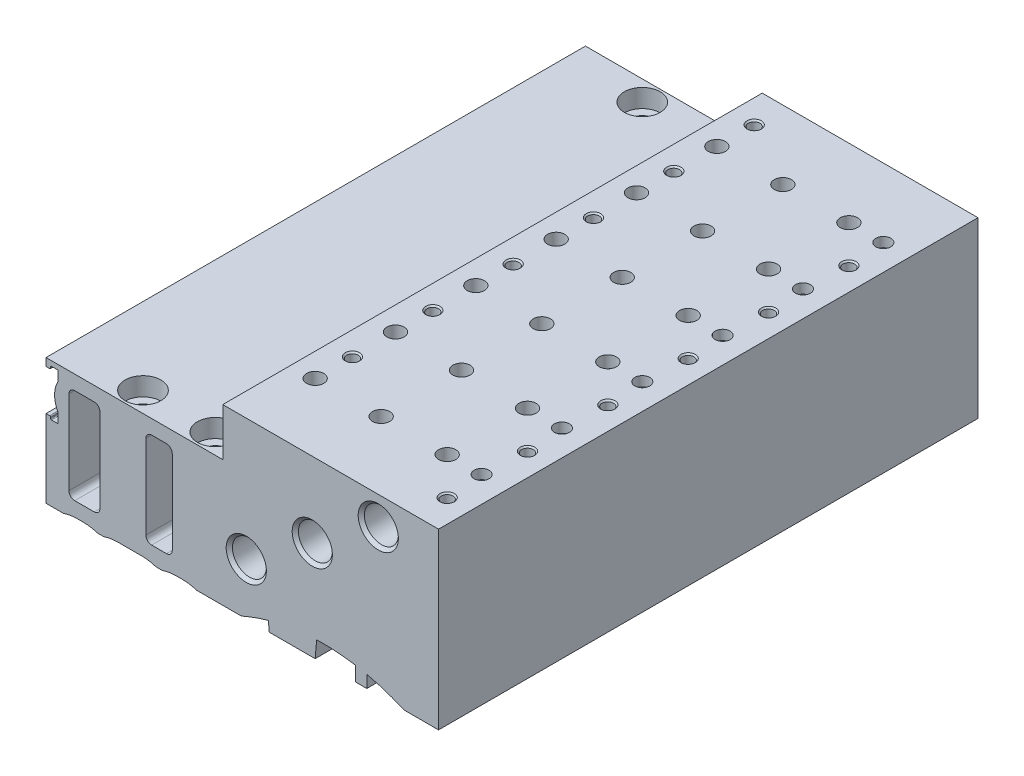
from build123d import *

# Parameters (mm, degrees)
BOSS_EXTRUDE1_DEPTH = 94
HOLE1_D             = 3.7
HOLE1_DEPTH         = 9
HOLE1_TIP           = 1.068097998
HOLE2_D             = 3.7
HOLE2_DEPTH         = 9
HOLE2_TIP           = 1.068097998
SKETCH13_R          = 1.5
CUT_EXTRUDE1_DEPTH  = 7
LPATTERN1_COUNT     = 6
LPATTERN1_PITCH     = 14
SKETCH15_R          = 1.5
CUT_EXTRUDE2_DEPTH  = 12
LPATTERN2_COUNT     = 6
LPATTERN2_PITCH     = 14
SKETCH17_R          = 1.5
CUT_EXTRUDE3_DEPTH  = 22
LPATTERN3_COUNT     = 6
LPATTERN3_PITCH     = 14
SKETCH19_R          = 1.3
CUT_EXTRUDE4_DEPTH  = 1.7
LPATTERN4_COUNT     = 6
LPATTERN4_PITCH     = 14
LPATTERN5_COUNT     = 6
LPATTERN5_PITCH     = 14
LPATTERN6_COUNT     = 6
LPATTERN6_PITCH     = 14


with BuildPart() as part:
    # Sketch1 → Boss-Extrude1 (new body)
    with BuildSketch(Plane.XY):
        with BuildLine():
            Line((-68.4, 20.65), (-67.75, 20.65))
            ThreePointArc((-67.75, 20.65), (-67.643933983, 20.693933983), (-67.6, 20.8))
            Line((-67.6, 20.8), (-67.6, 21))
            ThreePointArc((-67.6, 21), (-67.556066017, 21.106066017), (-67.45, 21.15))
            Line((-67.45, 21.15), (-66.45, 21.15))
            ThreePointArc((-66.45, 21.15), (-66.343933983, 21.106066017), (-66.3, 21))
            Line((-66.3, 21), (-66.3, 19.423790008))
            ThreePointArc((-66.3, 19.423790008), (-66.9, 17.1), (-66.3, 14.776209992))
            Line((-66.3, 14.776209992), (-66.3, 13.2))
            ThreePointArc((-66.3, 13.2), (-66.343933983, 13.093933983), (-66.45, 13.05))
            Line((-66.45, 13.05), (-67.45, 13.05))
            ThreePointArc((-67.45, 13.05), (-67.556066017, 13.093933983), (-67.6, 13.2))
            Line((-67.6, 13.2), (-67.6, 13.4))
            ThreePointArc((-67.6, 13.4), (-67.643933983, 13.506066017), (-67.75, 13.55))
            Line((-67.75, 13.55), (-68.4, 13.55))
            Line((-68.4, 13.55), (-68.4, 0))
            Line((-68.4, 0), (-65.399489743, 0))
            ThreePointArc((-65.399489743, 0), (-64.190967365, 0.299342077), (-62.95, 0.4))
            Line((-62.95, 0.4), (-61.9, 0.4))
            ThreePointArc((-61.9, 0.4), (-60.659032635, 0.299342077), (-59.450510257, 0))
            Line((-59.450510257, 0), (-58.349489743, 0))
            ThreePointArc((-58.349489743, 0), (-57.140967365, 0.299342077), (-55.9, 0.4))
            Line((-55.9, 0.4), (-51.7, 0.4))
            ThreePointArc((-51.7, 0.4), (-50.459032635, 0.299342077), (-49.250510257, 0))
            Line((-49.250510257, 0), (-48.149489743, 0))
            ThreePointArc((-48.149489743, 0), (-46.940967365, 0.299342077), (-45.7, 0.4))
            Line((-45.7, 0.4), (-44.6, 0.4))
            ThreePointArc((-44.6, 0.4), (-43.359032635, 0.299342077), (-42.150510257, 0))
            Line((-42.150510257, 0), (-34.377446879, 0))
            ThreePointArc((-34.377446879, 0), (-32.04366607, 0.935202656), (-29.648770622, 1.700455987))
            Line((-29.648770622, 1.700455987), (-29.5, 0))
            Line((-29.5, 0), (-21.5, 0))
            Line((-21.5, 0), (-21.23888323, 2.98457834))
            ThreePointArc((-21.23888323, 2.98457834), (-17.858517075, 2.921590137), (-14.5, 2.53273809))
            Line((-14.5, 2.53273809), (-14.5, 0))
            Line((-14.5, 0), (-12.5, 0))
            Line((-12.5, 0), (-12.5, 2.142495515))
            ThreePointArc((-12.5, 2.142495515), (-9.208947173, 1.229456176), (-6.022553121, 0))
            Line((-6.022553121, 0), (0, 0))
            Line((0, 0), (0, 30.3))
            Line((0, 30.3), (-37.6, 30.3))
            Line((-37.6, 30.3), (-37.6, 22))
            Line((-37.6, 22), (-68.4, 22))
            Line((-68.4, 22), (-68.4, 20.65))
        make_face()
        with BuildLine():
            Line((-51, 18.5), (-51, 3.9))
            ThreePointArc((-51, 3.9), (-50.707106781, 3.192893219), (-50, 2.9))
            Line((-50, 2.9), (-47.4, 2.9))
            ThreePointArc((-47.4, 2.9), (-46.692893219, 3.192893219), (-46.4, 3.9))
            Line((-46.4, 3.9), (-46.4, 18.5))
            ThreePointArc((-46.4, 18.5), (-46.692893219, 19.207106781), (-47.4, 19.5))
            Line((-47.4, 19.5), (-50, 19.5))
            ThreePointArc((-50, 19.5), (-50.707106781, 19.207106781), (-51, 18.5))
        make_face(mode=Mode.SUBTRACT)
        with BuildLine():
            Line((-64.4, 18.5), (-64.4, 3.9))
            ThreePointArc((-64.4, 3.9), (-64.107106781, 3.192893219), (-63.4, 2.9))
            Line((-63.4, 2.9), (-60, 2.9))
            ThreePointArc((-60, 2.9), (-59.292893219, 3.192893219), (-59, 3.9))
            Line((-59, 3.9), (-59, 18.5))
            ThreePointArc((-59, 18.5), (-59.292893219, 19.207106781), (-60, 19.5))
            Line((-60, 19.5), (-63.4, 19.5))
            ThreePointArc((-63.4, 19.5), (-64.107106781, 19.207106781), (-64.4, 18.5))
        make_face(mode=Mode.SUBTRACT)
    extrude(amount=BOSS_EXTRUDE1_DEPTH)

    # Hole1
    with Locations(Plane(origin=(0, 0, 0), x_dir=(-1, 0, 0), z_dir=(0, -1, 0))):
        with Locations((25.5, -6.5)):
            Hole(HOLE1_D / 2, depth=HOLE1_DEPTH)
            with Locations((0, 0, -(HOLE1_DEPTH + HOLE1_TIP / 2))):  # 120° drill point
                Cone(0, HOLE1_D / 2, HOLE1_TIP, mode=Mode.SUBTRACT)

    # Hole2
    with Locations(Plane(origin=(0, 0, 0), x_dir=(-1, 0, 0), z_dir=(0, -1, 0))):
        with Locations((25.5, -87.5)):
            Hole(HOLE2_D / 2, depth=HOLE2_DEPTH)
            with Locations((0, 0, -(HOLE2_DEPTH + HOLE2_TIP / 2))):  # 120° drill point
                Cone(0, HOLE2_D / 2, HOLE2_TIP, mode=Mode.SUBTRACT)

    # Sketch6 → Cut-Revolve1 (revolve, cut)
    with BuildSketch(Plane(origin=(-33.5, 0, 0), x_dir=(0, 0, -1), z_dir=(1, 0, 0))):
        Polygon((-94, 9), (-94, 12.5), (-93.4585, 11.9585), (-0.5415, 11.9585), (0, 12.5), (0, 9), align=None)
    revolve(axis=Axis((-33.5, 9, 0), (0, 0, 1)), mode=Mode.SUBTRACT)

    # Sketch7 → Cut-Revolve2 (revolve, cut)
    with BuildSketch(Plane(origin=(-22, 0, 0), x_dir=(0, 0, -1), z_dir=(1, 0, 0))):
        Polygon((-94, 17.2), (-94, 20.7), (-93.4585, 20.1585), (-0.5415, 20.1585), (0, 20.7), (0, 17.2), align=None)
    revolve(axis=Axis((-22, 17.2, 0), (0, 0, 1)), mode=Mode.SUBTRACT)

    # Sketch8 → Cut-Revolve3 (revolve, cut)
    with BuildSketch(Plane(origin=(-10.5, 0, 0), x_dir=(0, 0, -1), z_dir=(1, 0, 0))):
        Polygon((-94, 25.4), (-94, 28.9), (-93.4585, 28.3585), (-0.5415, 28.3585), (0, 28.9), (0, 25.4), align=None)
    revolve(axis=Axis((-10.5, 25.4, 0), (0, 0, 1)), mode=Mode.SUBTRACT)

    # Sketch9 → Cut-Revolve4 (revolve, cut)
    with BuildSketch(Plane.XY.offset(3.5)):
        Polygon((-55, 22), (-51.875, 22), (-51.875, 18.8), (-53.35, 18.8), (-53.35, 0), (-55, 0), align=None)
    revolve(axis=Axis((-55, 0, 3.5), (0, 1, 0)), mode=Mode.SUBTRACT)

    # Sketch10 → Cut-Revolve5 (revolve, cut)
    with BuildSketch(Plane.XY.offset(3.5)):
        Polygon((-42.4, 22), (-39.275, 22), (-39.275, 18.8), (-40.75, 18.8), (-40.75, 0), (-42.4, 0), align=None)
    revolve(axis=Axis((-42.4, 0, 3.5), (0, 1, 0)), mode=Mode.SUBTRACT)

    # Sketch11 → Cut-Revolve6 (revolve, cut)
    with BuildSketch(Plane.XY.offset(90.5)):
        Polygon((-55, 22), (-51.875, 22), (-51.875, 18.8), (-53.35, 18.8), (-53.35, 0), (-55, 0), align=None)
    revolve(axis=Axis((-55, 0, 90.5), (0, 1, 0)), mode=Mode.SUBTRACT)

    # Sketch12 → Cut-Revolve7 (revolve, cut)
    with BuildSketch(Plane.XY.offset(90.5)):
        Polygon((-42.4, 22), (-39.275, 22), (-39.275, 18.8), (-40.75, 18.8), (-40.75, 0), (-42.4, 0), align=None)
    revolve(axis=Axis((-42.4, 0, 90.5), (0, 1, 0)), mode=Mode.SUBTRACT)

    # Sketch13 → Cut-Extrude1 (cut)
    with BuildSketch(Plane(origin=(0, 30.3, 0), x_dir=(1, 0, 0), z_dir=(0, 1, 0))):
        with Locations((-10.5, -82)):
            Circle(SKETCH13_R)
    cut_extrude1 = extrude(amount=-CUT_EXTRUDE1_DEPTH, mode=Mode.SUBTRACT)

    # LPattern1: Cut-Extrude1 ×6
    with Locations(*[(0, 0, -i * LPATTERN1_PITCH) for i in range(1, LPATTERN1_COUNT)]):
        add(cut_extrude1, mode=Mode.SUBTRACT)

    # Sketch15 → Cut-Extrude2 (cut)
    with BuildSketch(Plane(origin=(0, 30.3, 0), x_dir=(1, 0, 0), z_dir=(0, 1, 0))):
        with Locations((-22, -82)):
            Circle(SKETCH15_R)
    cut_extrude2 = extrude(amount=-CUT_EXTRUDE2_DEPTH, mode=Mode.SUBTRACT)

    # LPattern2: Cut-Extrude2 ×6
    with Locations(*[(0, 0, -i * LPATTERN2_PITCH) for i in range(1, LPATTERN2_COUNT)]):
        add(cut_extrude2, mode=Mode.SUBTRACT)

    # Sketch17 → Cut-Extrude3 (cut)
    with BuildSketch(Plane(origin=(0, 30.3, 0), x_dir=(1, 0, 0), z_dir=(0, 1, 0))):
        with Locations((-33.5, -82)):
            Circle(SKETCH17_R)
    cut_extrude3 = extrude(amount=-CUT_EXTRUDE3_DEPTH, mode=Mode.SUBTRACT)

    # LPattern3: Cut-Extrude3 ×6
    with Locations(*[(0, 0, -i * LPATTERN3_PITCH) for i in range(1, LPATTERN3_COUNT)]):
        add(cut_extrude3, mode=Mode.SUBTRACT)

    # Sketch19 → Cut-Extrude4 (cut)
    with BuildSketch(Plane(origin=(0, 30.3, 0), x_dir=(1, 0, 0), z_dir=(0, 1, 0))):
        with Locations((-4.5, -82)):
            Circle(SKETCH19_R)
    cut_extrude4 = extrude(amount=-CUT_EXTRUDE4_DEPTH, mode=Mode.SUBTRACT)

    # LPattern4: Cut-Extrude4 ×6
    with Locations(*[(0, 0, -i * LPATTERN4_PITCH) for i in range(1, LPATTERN4_COUNT)]):
        add(cut_extrude4, mode=Mode.SUBTRACT)

    # Sketch21 → Cut-Revolve8 (revolve, cut)
    with BuildSketch(Plane(origin=(-33.5, 0, 0), x_dir=(0, 0, -1), z_dir=(1, 0, 0))):
        Polygon((-75.5, 30.3), (-74.25, 30.3), (-74.4935, 30.0565), (-74.4935, 25.7), (-75.5, 25.7), align=None)
    cut_revolve8 = revolve(axis=Axis((-33.5, 25.7, 75.5), (0, 1, 0)), mode=Mode.SUBTRACT)

    # LPattern5: Cut-Revolve8 ×6
    with Locations(*[(0, 0, -i * LPATTERN5_PITCH) for i in range(1, LPATTERN5_COUNT)]):
        add(cut_revolve8, mode=Mode.SUBTRACT)

    # Sketch23 → Cut-Revolve9 (revolve, cut)
    with BuildSketch(Plane(origin=(-4, 0, 0), x_dir=(0, 0, -1), z_dir=(1, 0, 0))):
        Polygon((-88.5, 30.3), (-87.25, 30.3), (-87.4935, 30.0565), (-87.4935, 25.7), (-88.5, 25.7), align=None)
    cut_revolve9 = revolve(axis=Axis((-4, 25.7, 88.5), (0, 1, 0)), mode=Mode.SUBTRACT)

    # LPattern6: Cut-Revolve9 ×6
    with Locations(*[(0, 0, -i * LPATTERN6_PITCH) for i in range(1, LPATTERN6_COUNT)]):
        add(cut_revolve9, mode=Mode.SUBTRACT)


solid = part.part
